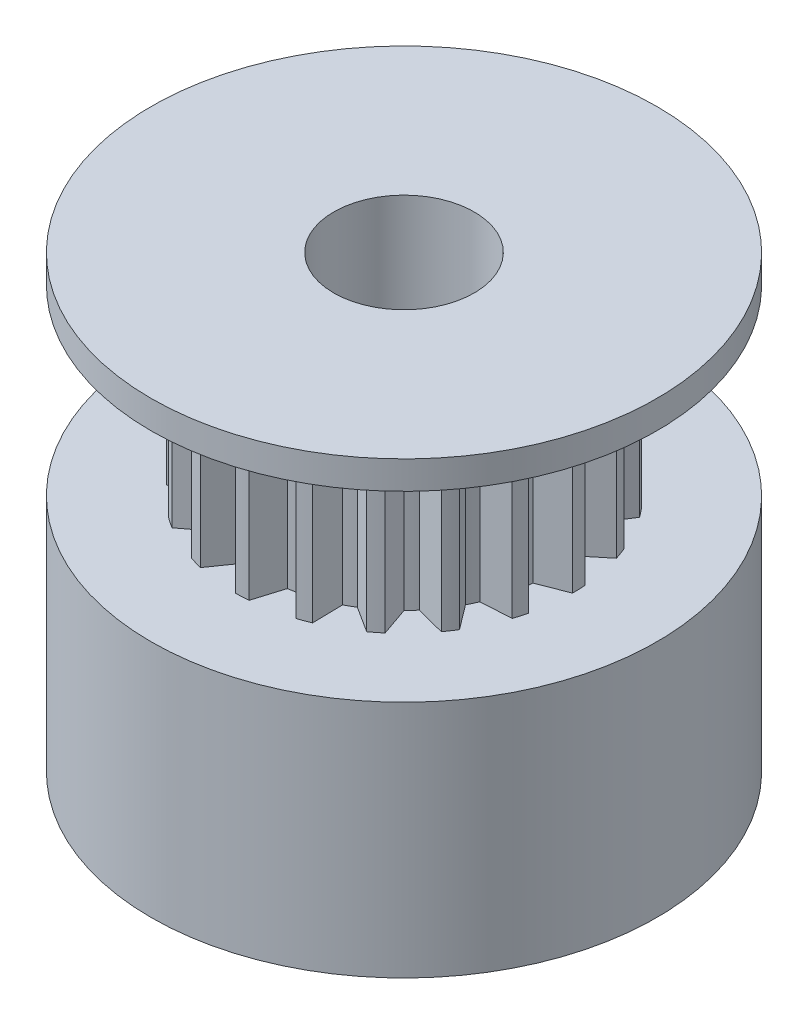
from build123d import *

# Parameters (mm, degrees)
SKETCH_1_R          = 9
EXTRUDE_1_DEPTH     = 8.5
SKETCH_2_R          = 6
EXTRUDE_2_DEPTH     = 6.5
SKETCH_3_R          = 9
EXTRUDE_3_DEPTH     = 1
SKETCH_4_R          = 2.5
CUT_EXTRUDE_1_DEPTH = 17
CUT_EXTRUDE_2_DEPTH = 6.5


with BuildPart() as part:
    # 草图1 → 凸台-拉伸1 (new body)
    with BuildSketch(Plane(origin=(0, 0, 0), x_dir=(1, 0, 0), z_dir=(0, 1, 0))):
        Circle(SKETCH_1_R)
    extrude(amount=EXTRUDE_1_DEPTH)

    # 草图2 → 凸台-拉伸2 (add)
    with BuildSketch(Plane(origin=(0, 8.5, 0), x_dir=(1, 0, 0), z_dir=(0, 1, 0))):
        Circle(SKETCH_2_R)
    extrude(amount=EXTRUDE_2_DEPTH)

    # 草图3 → 凸台-拉伸3 (add)
    with BuildSketch(Plane(origin=(0, 15, 0), x_dir=(1, 0, 0), z_dir=(0, 1, 0))):
        Circle(SKETCH_3_R)
    extrude(amount=EXTRUDE_3_DEPTH)

    # 草图4 → 切除-拉伸1 (cut, through all)
    with BuildSketch(Plane(origin=(0, 16, 0), x_dir=(1, 0, 0), z_dir=(0, 1, 0))):
        Circle(SKETCH_4_R)
    extrude(amount=-CUT_EXTRUDE_1_DEPTH, mode=Mode.SUBTRACT)

    # 草图5 → 切除-拉伸2 (cut)
    with BuildSketch(Plane(origin=(0, 8.5, 0), x_dir=(1, 0, 0), z_dir=(0, 1, 0))):
        with BuildLine():
            Line((-6, 0), (-4.984088538, 0.398574263))
            ThreePointArc((-4.984088538, 0.398574263), (-4.96506054, 0.590062568), (-4.938678327, 0.780676876))
            Line((-4.938678327, 0.780676876), (-5.83314158, 1.40515455))
            ThreePointArc((-5.83314158, 1.40515455), (-5.958139369, 0.707513435), (-6, 0))
        make_face()
        with BuildLine():
            Line((-5.981863946, -0.466158487), (-4.938204626, -0.783667703))
            ThreePointArc((-4.938204626, -0.783667703), (-4.904392542, -0.973105234), (-4.863316103, -1.161101409))
            Line((-4.863316103, -1.161101409), (-5.706339098, -1.854101966))
            ThreePointArc((-5.706339098, -1.854101966), (-5.885160947, -1.168281057), (-5.981863946, -0.466158487))
        make_face()
        with BuildLine():
            Line((-5.706339098, 1.854101966), (-4.616983661, 1.91923471))
            ThreePointArc((-4.616983661, 1.91923471), (-4.539713819, 2.095470935), (-4.455719783, 2.268603363))
            Line((-4.455719783, 2.268603363), (-5.113430674, 3.13892127))
            ThreePointArc((-5.113430674, 3.13892127), (-5.447893597, 2.514051583), (-5.706339098, 1.854101966))
        make_face()
        with BuildLine():
            Line((-4.854101966, 3.526711514), (-3.797936255, 3.252027091))
            ThreePointArc((-3.797936255, 3.252027091), (-3.669988279, 3.395760008), (-3.536604341, 3.534463146))
            Line((-3.536604341, 3.534463146), (-3.893181547, 4.565428506))
            ThreePointArc((-3.893181547, 4.565428506), (-4.404370041, 4.074496845), (-4.854101966, 3.526711514))
        make_face()
        with BuildLine():
            Line((-3.526711514, 4.854101966), (-2.607120386, 4.266488403))
            ThreePointArc((-2.607120386, 4.266488403), (-2.441018717, 4.36364843), (-2.271301426, 4.454345051))
            Line((-2.271301426, 4.454345051), (-2.291840684, 5.545039791))
            ThreePointArc((-2.291840684, 5.545039791), (-2.929716059, 5.236101967), (-3.526711514, 4.854101966))
        make_face()
        with BuildLine():
            Line((-1.854101966, 5.706339098), (-1.161101409, 4.863316103))
            ThreePointArc((-1.161101409, 4.863316103), (-0.973105234, 4.904392542), (-0.783667703, 4.938204626))
            Line((-0.783667703, 4.938204626), (-0.466158487, 5.981863946))
            ThreePointArc((-0.466158487, 5.981863946), (-1.168281057, 5.885160947), (-1.854101966, 5.706339098))
        make_face()
        with BuildLine():
            Line((0, 6), (0.398574263, 4.984088538))
            ThreePointArc((0.398574263, 4.984088538), (0.590062568, 4.96506054), (0.780676876, 4.938678327))
            Line((0.780676876, 4.938678327), (1.40515455, 5.83314158))
            ThreePointArc((1.40515455, 5.83314158), (0.707513435, 5.958139369), (0, 6))
        make_face()
        with BuildLine():
            Line((1.854101966, 5.706339098), (1.91923471, 4.616983661))
            ThreePointArc((1.91923471, 4.616983661), (2.095470935, 4.539713819), (2.268603363, 4.455719783))
            Line((2.268603363, 4.455719783), (3.13892127, 5.113430674))
            ThreePointArc((3.13892127, 5.113430674), (2.514051583, 5.447893597), (1.854101966, 5.706339098))
        make_face()
        with BuildLine():
            Line((3.526711514, 4.854101966), (3.252027091, 3.797936255))
            ThreePointArc((3.252027091, 3.797936255), (3.395760008, 3.669988279), (3.534463146, 3.536604341))
            Line((3.534463146, 3.536604341), (4.565428506, 3.893181547))
            ThreePointArc((4.565428506, 3.893181547), (4.074496845, 4.404370041), (3.526711514, 4.854101966))
        make_face()
        with BuildLine():
            Line((4.854101966, 3.526711514), (4.266488403, 2.607120386))
            ThreePointArc((4.266488403, 2.607120386), (4.36364843, 2.441018717), (4.454345051, 2.271301426))
            Line((4.454345051, 2.271301426), (5.545039791, 2.291840684))
            ThreePointArc((5.545039791, 2.291840684), (5.236101967, 2.929716059), (4.854101966, 3.526711514))
        make_face()
        with BuildLine():
            Line((5.706339098, 1.854101966), (4.863316103, 1.161101409))
            ThreePointArc((4.863316103, 1.161101409), (4.904392542, 0.973105234), (4.938204626, 0.783667703))
            Line((4.938204626, 0.783667703), (5.981863946, 0.466158487))
            ThreePointArc((5.981863946, 0.466158487), (5.885160947, 1.168281057), (5.706339098, 1.854101966))
        make_face()
        with BuildLine():
            Line((6, 0), (4.984088538, -0.398574263))
            ThreePointArc((4.984088538, -0.398574263), (4.96506054, -0.590062568), (4.938678327, -0.780676876))
            Line((4.938678327, -0.780676876), (5.83314158, -1.40515455))
            ThreePointArc((5.83314158, -1.40515455), (5.958139369, -0.707513435), (6, 0))
        make_face()
        with BuildLine():
            Line((5.706339098, -1.854101966), (4.616983661, -1.91923471))
            ThreePointArc((4.616983661, -1.91923471), (4.539713819, -2.095470935), (4.455719783, -2.268603363))
            Line((4.455719783, -2.268603363), (5.113430674, -3.13892127))
            ThreePointArc((5.113430674, -3.13892127), (5.447893597, -2.514051583), (5.706339098, -1.854101966))
        make_face()
        with BuildLine():
            Line((4.854101966, -3.526711514), (3.797936255, -3.252027091))
            ThreePointArc((3.797936255, -3.252027091), (3.669988279, -3.395760008), (3.536604341, -3.534463146))
            Line((3.536604341, -3.534463146), (3.893181547, -4.565428506))
            ThreePointArc((3.893181547, -4.565428506), (4.404370041, -4.074496845), (4.854101966, -3.526711514))
        make_face()
        with BuildLine():
            Line((3.526711514, -4.854101966), (2.607120386, -4.266488403))
            ThreePointArc((2.607120386, -4.266488403), (2.441018717, -4.36364843), (2.271301426, -4.454345051))
            Line((2.271301426, -4.454345051), (2.291840684, -5.545039791))
            ThreePointArc((2.291840684, -5.545039791), (2.929716059, -5.236101967), (3.526711514, -4.854101966))
        make_face()
        with BuildLine():
            Line((1.854101966, -5.706339098), (1.161101409, -4.863316103))
            ThreePointArc((1.161101409, -4.863316103), (0.973105234, -4.904392542), (0.783667703, -4.938204626))
            Line((0.783667703, -4.938204626), (0.466158487, -5.981863946))
            ThreePointArc((0.466158487, -5.981863946), (1.168281057, -5.885160947), (1.854101966, -5.706339098))
        make_face()
        with BuildLine():
            Line((0, -6), (-0.398574263, -4.984088538))
            ThreePointArc((-0.398574263, -4.984088538), (-0.590062568, -4.96506054), (-0.780676876, -4.938678327))
            Line((-0.780676876, -4.938678327), (-1.40515455, -5.83314158))
            ThreePointArc((-1.40515455, -5.83314158), (-0.707513435, -5.958139369), (0, -6))
        make_face()
        with BuildLine():
            Line((-1.854101966, -5.706339098), (-1.91923471, -4.616983661))
            ThreePointArc((-1.91923471, -4.616983661), (-2.095470935, -4.539713819), (-2.268603363, -4.455719783))
            Line((-2.268603363, -4.455719783), (-3.13892127, -5.113430674))
            ThreePointArc((-3.13892127, -5.113430674), (-2.514051583, -5.447893597), (-1.854101966, -5.706339098))
        make_face()
        with BuildLine():
            Line((-3.526711514, -4.854101966), (-3.252027091, -3.797936255))
            ThreePointArc((-3.252027091, -3.797936255), (-3.395760008, -3.669988279), (-3.534463146, -3.536604341))
            Line((-3.534463146, -3.536604341), (-4.565428506, -3.893181547))
            ThreePointArc((-4.565428506, -3.893181547), (-4.074496845, -4.404370041), (-3.526711514, -4.854101966))
        make_face()
        with BuildLine():
            Line((-4.854101966, -3.526711514), (-4.266488403, -2.607120386))
            ThreePointArc((-4.266488403, -2.607120386), (-4.36364843, -2.441018717), (-4.454345051, -2.271301426))
            Line((-4.454345051, -2.271301426), (-5.545039791, -2.291840684))
            ThreePointArc((-5.545039791, -2.291840684), (-5.236101967, -2.929716059), (-4.854101966, -3.526711514))
        make_face()
    extrude(amount=CUT_EXTRUDE_2_DEPTH, mode=Mode.SUBTRACT)


solid = part.part
